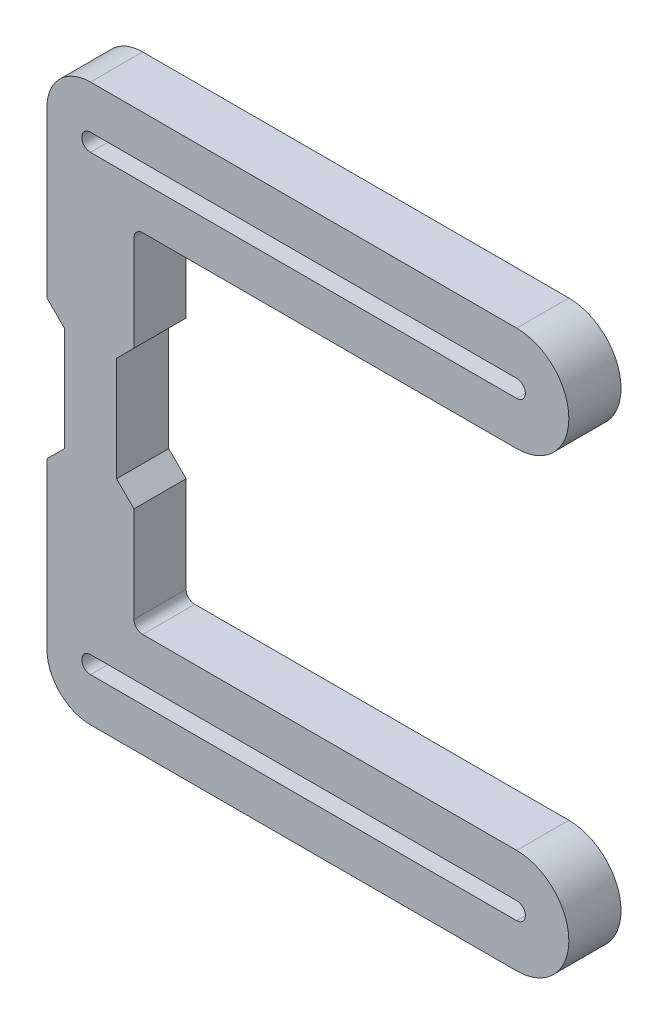
from build123d import *

# Parameters (mm, degrees)
BOSS_EXTRUDE1_DEPTH = 6


with BuildPart() as part:
    # Sketch1 → Boss-Extrude1 (new body)
    with BuildSketch(Plane.XY):
        with BuildLine():
            Line((3, 6), (5, 8))
            Line((5, 8), (5, 19))
            ThreePointArc((5, 19), (5.292893219, 19.707106781), (6, 20))
            Line((6, 20), (49, 20))
            ThreePointArc((49, 20), (55, 26), (49, 32))
            Line((49, 32), (0, 32))
            ThreePointArc((0, 32), (-3.535533906, 30.535533906), (-5, 27))
            Line((-5, 27), (-5, 8))
            Line((-5, 8), (-3, 6))
            Line((-3, 6), (-3, 0))
            Line((-3, 0), (3, 0))
            Line((3, 0), (3, 6))
        make_face()
        with BuildLine():
            Line((0, 27), (49, 27))
            ThreePointArc((49, 27), (50, 26), (49, 25))
            Line((49, 25), (0, 25))
            ThreePointArc((0, 25), (-1, 26), (0, 27))
        make_face(mode=Mode.SUBTRACT)
    boss_extrude1 = extrude(amount=BOSS_EXTRUDE1_DEPTH)

    # Mirror1: Boss-Extrude1 across plane
    add(boss_extrude1.mirror(Plane(origin=(-3, 0, 6), x_dir=(0, 0, 1), z_dir=(0, 1, 0))))


solid = part.part
